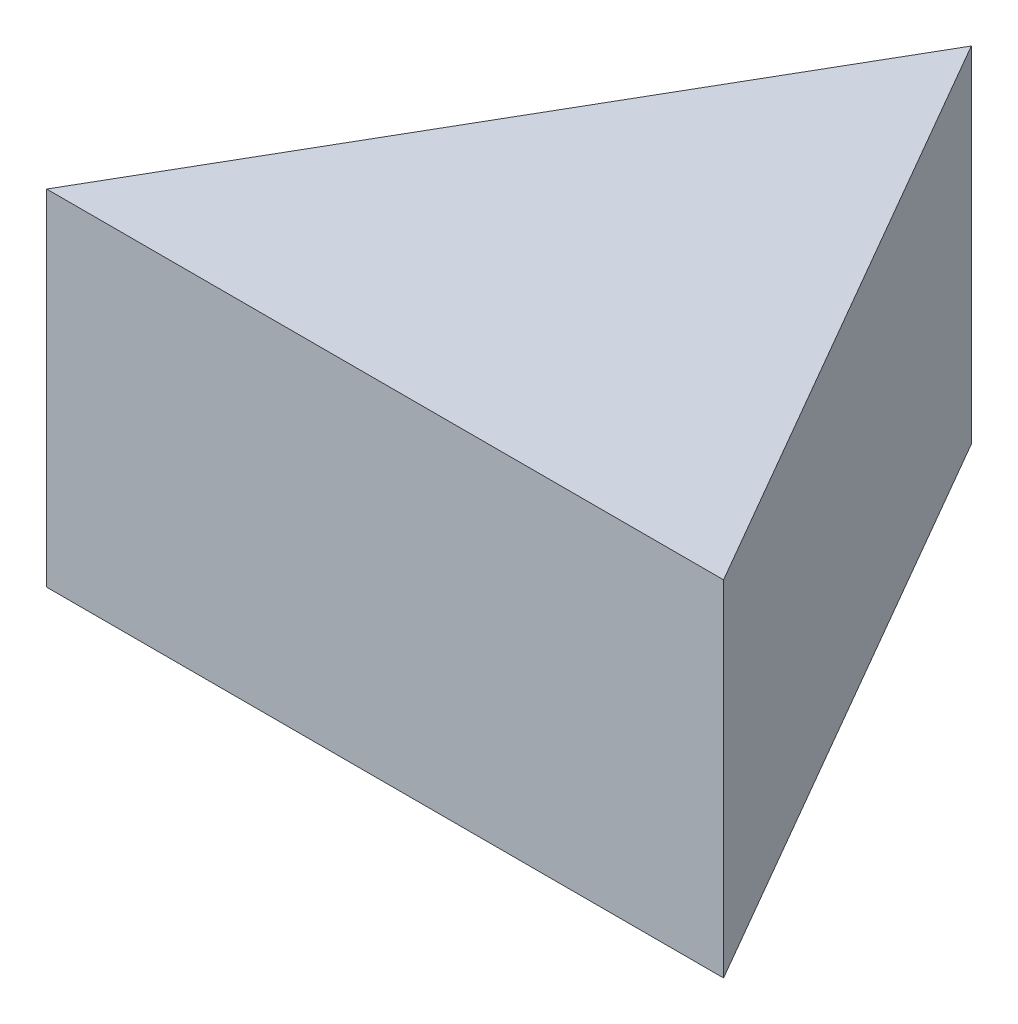
from build123d import *

# Parameters (mm, degrees)
BOSS_EXTRUDE1_DEPTH = 10


with BuildPart() as part:
    # Sketch1 → Boss-Extrude1 (new body)
    with BuildSketch(Plane(origin=(0, 0, 0), x_dir=(1, 0, 0), z_dir=(0, 1, 0))):
        Polygon((-7.407477288, 12.047518323), (-17.222431864, -4.952481677), (2.407477288, -4.952481677), align=None)
    extrude(amount=BOSS_EXTRUDE1_DEPTH)


solid = part.part
